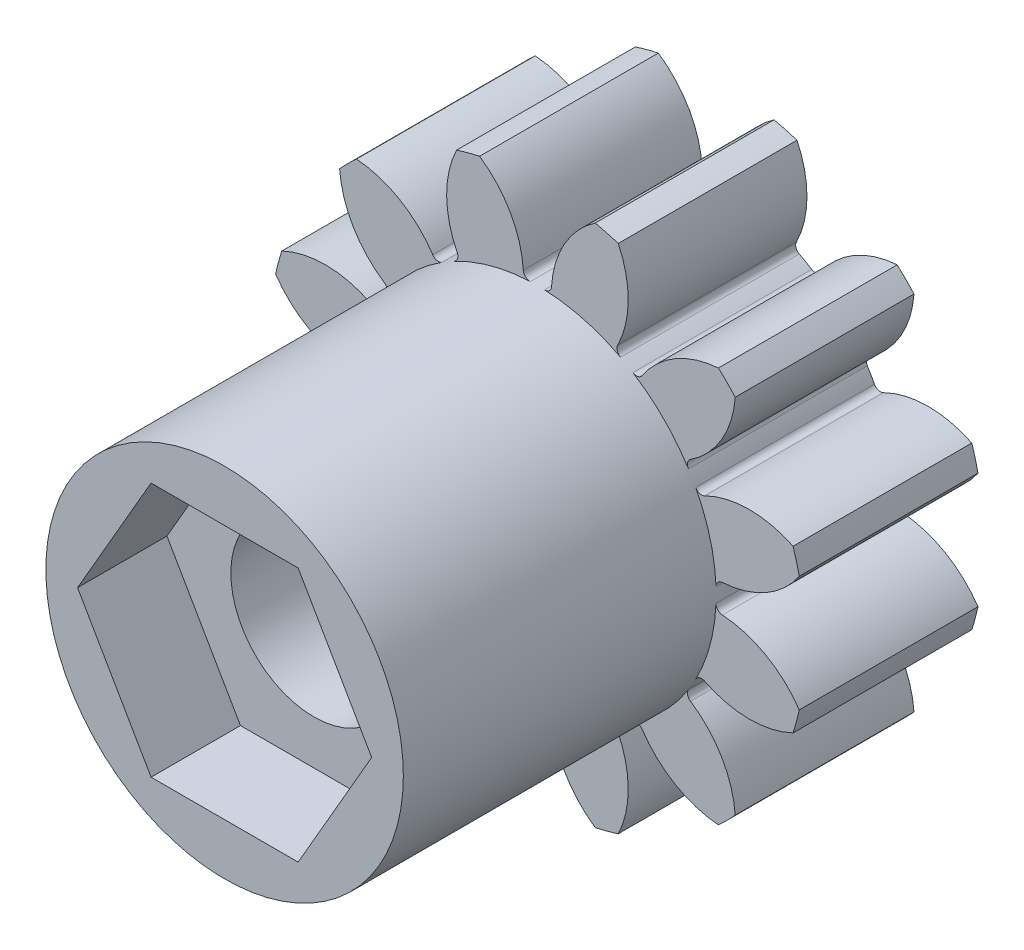
from build123d import *

# Parameters (mm, degrees)
SKETCH1_R           = 6
SKETCH1_R_2         = 2
BOSS_EXTRUDE1_DEPTH = 4
CUT_EXTRUDE2_DEPTH  = 5
CIRPATTERN2_COUNT   = 12
SKETCH11_R          = 4
BOSS_EXTRUDE2_DEPTH = 11
CUT_EXTRUDE3_START  = 11
CUT_EXTRUDE3_DEPTH  = 2
CUT_EXTRUDE4_DEPTH  = 12


with BuildPart() as part:
    # Sketch1 → Boss-Extrude1 (new body)
    with BuildSketch(Plane.XY):
        Circle(SKETCH1_R)
        Circle(SKETCH1_R_2, mode=Mode.SUBTRACT)
    extrude(amount=BOSS_EXTRUDE1_DEPTH)

    # Sketch4 → Cut-Extrude2 (cut, through all)
    with BuildSketch(Plane.XY):
        with BuildLine():
            ThreePointArc((-0.160215471, 3.996790087), (-0.266788325, 4.035374045), (-0.315943185, 4.137502858))
            ThreePointArc((-0.315943185, 4.137502858), (-0.829511973, 5.435929685), (-2.010193861, 6.181352655))
            ThreePointArc((-2.010193861, 6.181352655), (0, 6.5), (2.010193861, 6.181352655))
            ThreePointArc((2.010193861, 6.181352655), (0.829511973, 5.435929685), (0.315943185, 4.137502858))
            ThreePointArc((0.315943185, 4.137502858), (0.266788325, 4.035374045), (0.160215471, 3.996790087))
            ThreePointArc((0.160215471, 3.996790087), (0, 4), (-0.160215471, 3.996790087))
        make_face()
    cut_extrude2 = extrude(amount=CUT_EXTRUDE2_DEPTH, mode=Mode.SUBTRACT)

    # CirPattern2: Cut-Extrude2 ×12 about axis
    cirpattern2_axis = Axis((0, 0, 0), (0, 0, 1))
    for i in range(1, CIRPATTERN2_COUNT):
        add(cut_extrude2.rotate(cirpattern2_axis, i * 360 / CIRPATTERN2_COUNT), mode=Mode.SUBTRACT)

    # Sketch11 → Boss-Extrude2 (add)
    with BuildSketch(Plane.XY):
        Circle(SKETCH11_R)
    extrude(amount=BOSS_EXTRUDE2_DEPTH)

    # Sketch12 → Cut-Extrude3 (cut)
    with BuildSketch(Plane.XY.offset(CUT_EXTRUDE3_START)):
        Polygon((3.290896534, 0), (1.645448267, 2.85), (-1.645448267, 2.85), (-3.290896534, 0), (-1.645448267, -2.85), (1.645448267, -2.85), align=None)
    extrude(amount=-CUT_EXTRUDE3_DEPTH, mode=Mode.SUBTRACT)

    # Sketch13 → Cut-Extrude4 (cut, through all)
    with BuildSketch(Plane.XY):
        with BuildLine():
            Line((1.6, 0.95), (-1.6, 0.95))
            ThreePointArc((-1.6, 0.95), (0, -1.860779407), (1.6, 0.95))
        make_face()
    extrude(amount=CUT_EXTRUDE4_DEPTH, mode=Mode.SUBTRACT)


solid = part.part
